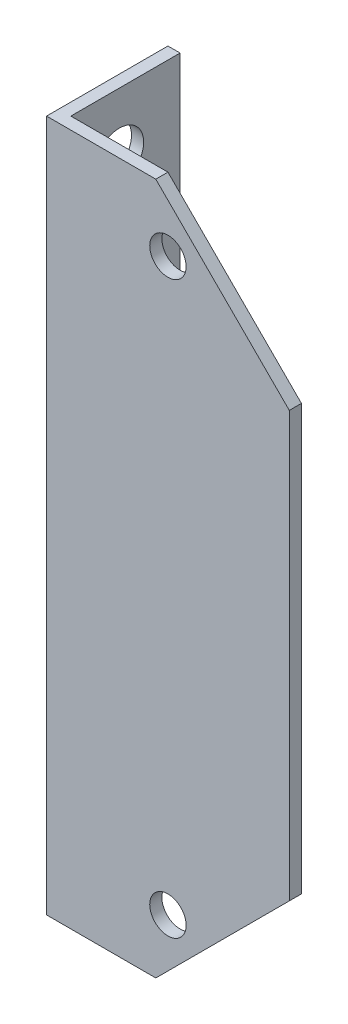
from build123d import *

# Parameters (mm, degrees)
BOSS_EXTRU_1_DEPTH      = 57
ESQUISSE2_R             = 2
ENL_V_MAT_EXTRU_1_DEPTH = 50
ESQUISSE3_R             = 1.5
ENL_V_MAT_EXTRU_2_DEPTH = 50


with BuildPart() as part:
    # Esquisse1 → Boss.-Extru.1 (new body)
    with BuildSketch(Plane(origin=(0, 0, 0), x_dir=(1, 0, 0), z_dir=(0, 1, 0))):
        Polygon((-11, 8.5), (-11, -1.5), (9, -1.5), (9, -0.5), (-10, -0.5), (-10, 8.5), align=None)
    extrude(amount=BOSS_EXTRU_1_DEPTH)

    # Esquisse2 → Enlèv. mat.-Extru.1 (cut)
    with BuildSketch(Plane.ZY.offset(11)):
        with Locations((-3.5, 52.14)):
            Circle(ESQUISSE2_R)
        with Locations((-3.5, 5)):
            Circle(ESQUISSE2_R)
    extrude(amount=-ENL_V_MAT_EXTRU_1_DEPTH, mode=Mode.SUBTRACT)

    # Esquisse3 → Enlèv. mat.-Extru.2 (cut)
    with BuildSketch(Plane(origin=(0, 0, 0.5), x_dir=(-1, 0, 0), z_dir=(0, 0, -1))):
        with Locations((1, 52)):
            Circle(ESQUISSE3_R)
        with Locations((1, 5)):
            Circle(ESQUISSE3_R)
        Polygon((2, 57), (-9, 46), (-9, 57), align=None)
        Polygon((-9, 0), (-9, 11), (2, 0), align=None)
    extrude(amount=-ENL_V_MAT_EXTRU_2_DEPTH, mode=Mode.SUBTRACT)


solid = part.part
